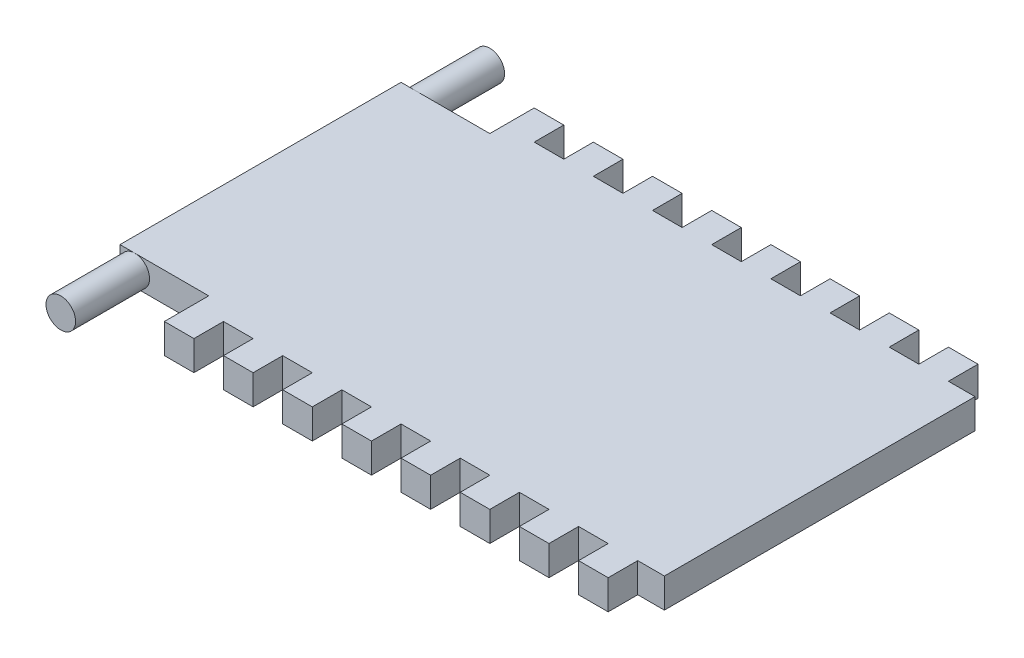
from build123d import *

# Parameters (mm, degrees)
ESQUISSE1_W                = 189
ESQUISSE1_H                = 125
BOSS_EXTRU_1_DEPTH         = 10
ESQUISSE2_W                = 30
ESQUISSE2_H                = 15
ENL_V_MAT_EXTRU_1_DEPTH    = 10
ESQUISSE3_W                = 10
ESQUISSE3_H                = 10
ENL_V_MAT_EXTRU_2_DEPTH    = 10
R_P_TITION_LIN_AIRE1_COUNT = 8
R_P_TITION_LIN_AIRE1_PITCH = 20
ESQUISSE4_R                = 5
BOSS_EXTRU_2_DEPTH         = 25
ESQUISSE5_R                = 5
BOSS_EXTRU_4_DEPTH         = 25


with BuildPart() as part:
    # Esquisse1 → Boss.-Extru.1 (new body)
    with BuildSketch(Plane(origin=(0, 0, 0), x_dir=(1, 0, 0), z_dir=(0, 1, 0))):
        with Locations((-94.5, 62.5)):
            Rectangle(ESQUISSE1_W, ESQUISSE1_H)
    extrude(amount=BOSS_EXTRU_1_DEPTH)

    # Esquisse2 → Enlèv. mat.-Extru.1 (cut)
    with BuildSketch(Plane(origin=(0, 10, 0), x_dir=(1, 0, 0), z_dir=(0, 1, 0))):
        with Locations((-174, 117.5)):
            Rectangle(ESQUISSE2_W, ESQUISSE2_H)
        with Locations((-174, 7.5)):
            Rectangle(ESQUISSE2_W, ESQUISSE2_H)
    extrude(amount=-ENL_V_MAT_EXTRU_1_DEPTH, mode=Mode.SUBTRACT)

    # Esquisse3 → Enlèv. mat.-Extru.2 (cut)
    with BuildSketch(Plane(origin=(0, 10, 0), x_dir=(1, 0, 0), z_dir=(0, 1, 0))):
        with Locations((-144, 120)):
            Rectangle(ESQUISSE3_W, ESQUISSE3_H)
        with Locations((-144, 5)):
            Rectangle(ESQUISSE3_W, ESQUISSE3_H)
    enl_v_mat_extru_2 = extrude(amount=-ENL_V_MAT_EXTRU_2_DEPTH, mode=Mode.SUBTRACT)

    # Répétition linéaire1: Enlèv. mat.-Extru.2 ×8
    with Locations(*[(i * R_P_TITION_LIN_AIRE1_PITCH, 0, 0) for i in range(1, R_P_TITION_LIN_AIRE1_COUNT)]):
        add(enl_v_mat_extru_2, mode=Mode.SUBTRACT)

    # Esquisse4 → Boss.-Extru.2 (add)
    with BuildSketch(Plane.XY.offset(-15)):
        with Locations((-184, 5)):
            Circle(ESQUISSE4_R)
    extrude(amount=BOSS_EXTRU_2_DEPTH)

    # Esquisse5 → Boss.-Extru.4 (add)
    with BuildSketch(Plane(origin=(0, 0, -110), x_dir=(-1, 0, 0), z_dir=(0, 0, -1))):
        with Locations((184, 5)):
            Circle(ESQUISSE5_R)
    extrude(amount=BOSS_EXTRU_4_DEPTH)


solid = part.part
